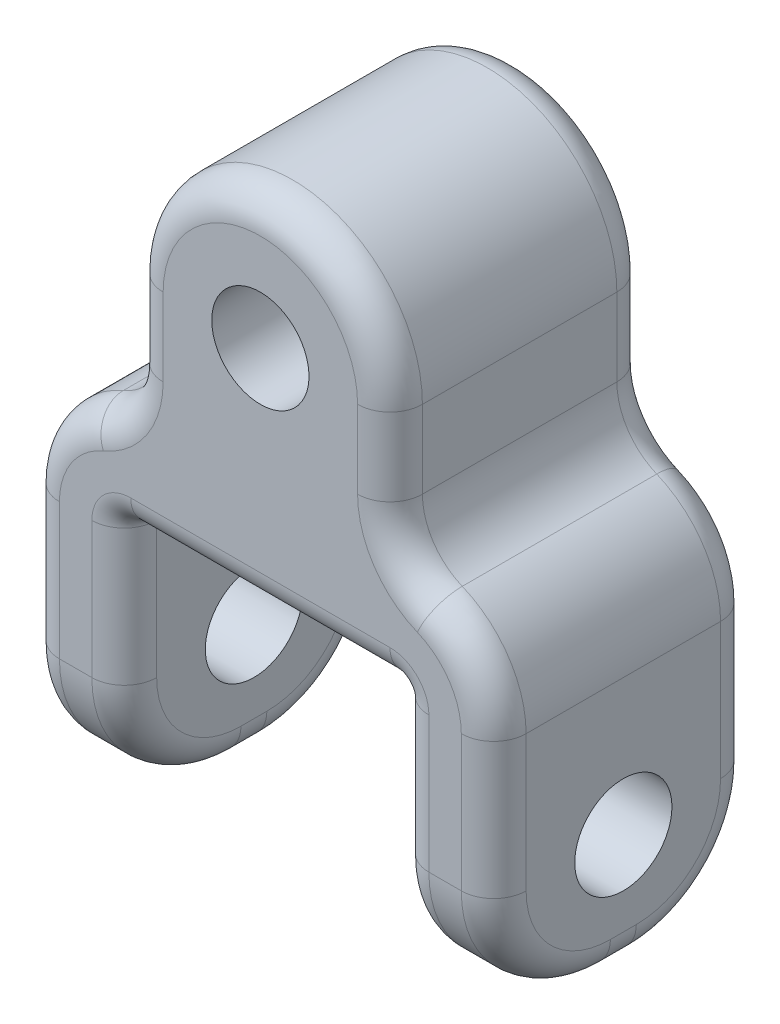
from build123d import *

# Parameters (mm, degrees)
BOSS_EXTRUDE2_DEPTH = 40
FILLET4_R           = 18
SKETCH8_R           = 7.5
CUT_EXTRUDE3_DEPTH  = 73
SKETCH9_R           = 7.5
CUT_EXTRUDE4_DEPTH  = 41
FILLET5_R           = 1
FILLET6_R           = 5


with BuildPart() as part:
    # Sketch7 → Boss-Extrude2 (new body)
    with BuildSketch(Plane.XY):
        with BuildLine():
            Line((-21, 40), (21, 40))
            Line((21, 40), (21, 0))
            Line((21, 0), (36, 0))
            Line((36, 0), (36, 39))
            ThreePointArc((36, 39), (33.312804709, 47.87520314), (26.153846154, 53.769230769))
            ThreePointArc((26.153846154, 53.769230769), (21.679497057, 57.452998038), (20, 63))
            Line((20, 63), (20, 75))
            ThreePointArc((20, 75), (0, 95), (-20, 75))
            Line((-20, 75), (-20, 63))
            ThreePointArc((-20, 63), (-21.679497057, 57.452998038), (-26.153846154, 53.769230769))
            ThreePointArc((-26.153846154, 53.769230769), (-33.312804709, 47.87520314), (-36, 39))
            Line((-36, 39), (-36, 0))
            Line((-36, 0), (-21, 0))
            Line((-21, 0), (-21, 40))
        make_face()
    extrude(amount=-BOSS_EXTRUDE2_DEPTH)

    # Fillet4
    fillet4_edges = [part.edges().sort_by_distance(p)[0] for p in [
        (28.5, 0, 0),
        (-28.5, 0, 0),
        (-28.5, 0, -40),
        (28.5, 0, -40),
    ]]
    fillet(fillet4_edges, radius=FILLET4_R)

    # Sketch8 → Cut-Extrude3 (cut, through all)
    with BuildSketch(Plane(origin=(36, 0, 0), x_dir=(0, 0, -1), z_dir=(1, 0, 0))):
        with Locations((20, 18)):
            Circle(SKETCH8_R)
    extrude(amount=-CUT_EXTRUDE3_DEPTH, mode=Mode.SUBTRACT)

    # Sketch9 → Cut-Extrude4 (cut, through all)
    with BuildSketch(Plane(origin=(0, 0, -40), x_dir=(-1, 0, 0), z_dir=(0, 0, -1))):
        with Locations((0, 75)):
            Circle(SKETCH9_R)
    extrude(amount=-CUT_EXTRUDE4_DEPTH, mode=Mode.SUBTRACT)

    # Fillet5
    fillet5_edges = [part.edges().sort_by_distance(p)[0] for p in [
        (21, 40, -20),
        (-21, 40, -20),
    ]]
    fillet(fillet5_edges, radius=FILLET5_R)

    # Fillet6
    fillet6_edges = [part.edges().sort_by_distance(p)[0] for p in [
        (20, 69, -40),
        (0, 95, -40),
        (-36, 28.5, 0),
        (-33.312804709, 47.87520314, 0),
        (-21.679497057, 57.452998038, 0),
        (-20, 69, -40),
        (-20, 69, 0),
        (0, 95, 0),
        (20, 69, 0),
        (21.679497057, 57.452998038, 0),
        (33.312804709, 47.87520314, 0),
        (-21.679497057, 57.452998038, -40),
        (-33.312804709, 47.87520314, -40),
        (-36, 28.5, -40),
        (33.312804709, 47.87520314, -40),
        (-36, 0, -20),
        (-21, 0, -20),
        (-21, 28.5, 0),
        (-21, 28.5, -40),
        (-21, 5.272077939, -5.272077939),
        (-21, 5.272077939, -34.727922061),
        (36, 28.5, -40),
        (-36, 5.272077939, -5.272077939),
        (-36, 5.272077939, -34.727922061),
        (21, 0, -20),
        (36, 0, -20),
        (36, 28.5, 0),
        (36, 5.272077939, -5.272077939),
        (36, 5.272077939, -34.727922061),
        (21, 5.272077939, -5.272077939),
        (21, 5.272077939, -34.727922061),
        (21.679497057, 57.452998038, -40),
        (0, 40, 0),
        (0, 40, -40),
        (21, 28.5, -40),
        (21, 28.5, 0),
        (-20.707106781, 39.707106781, 0),
        (-20.707106781, 39.707106781, -40),
        (20.707106781, 39.707106781, 0),
        (20.707106781, 39.707106781, -40),
    ]]
    fillet(fillet6_edges, radius=FILLET6_R)


solid = part.part
